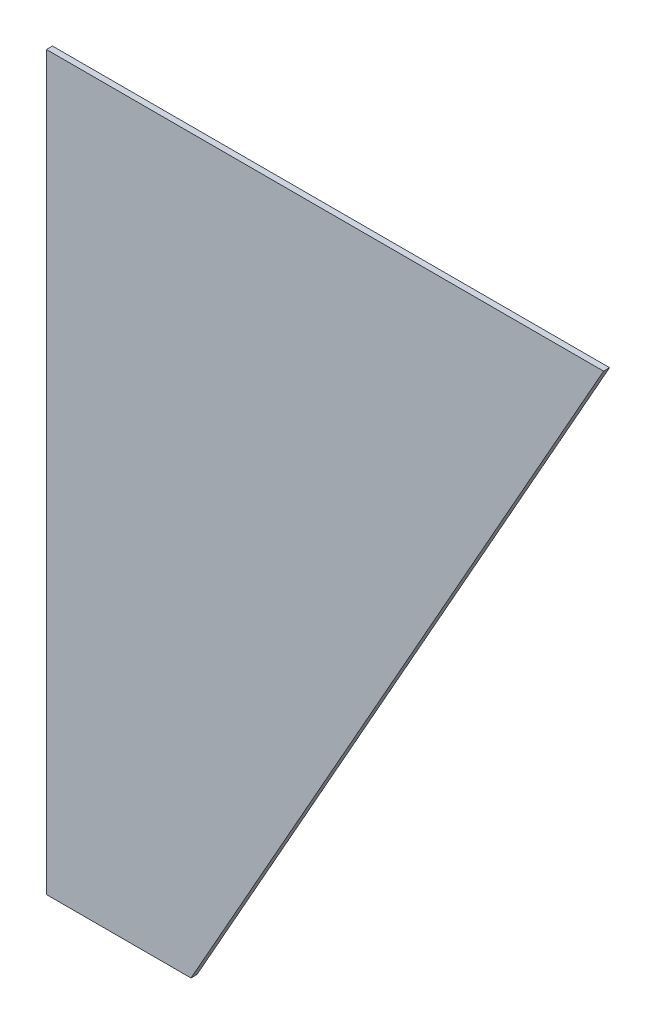
from build123d import *

# Parameters (mm, degrees)
RESSALTO_EXTRUS_O1_DEPTH = 2


with BuildPart() as part:
    # Esboço1 → Ressalto-extrusão1 (new body)
    with BuildSketch(Plane.XY):
        Polygon((0, 0), (185, 0), (48, -243), (0, -243), align=None)
    extrude(amount=RESSALTO_EXTRUS_O1_DEPTH)


solid = part.part
